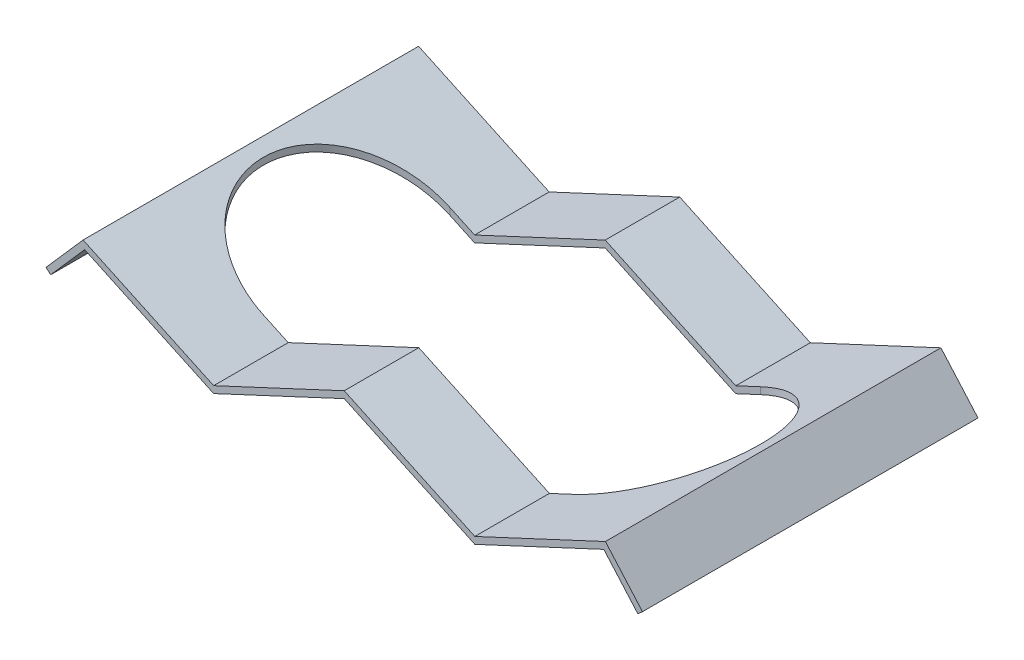
from build123d import *

# Parameters (mm, degrees)
EXTRU_MINCE1_DEPTH           = 13.5
ENL_V_MAT_EXTRU_1_DEPTH      = 3.45
ENL_V_MAT_EXTRU_1_DEPTH_BACK = 4.001688959


with BuildPart() as part:
    # Esquisse1 → Extru.-Mince1 (new body, symmetric)
    with BuildSketch(Plane.XY):
        Polygon((-24, -0.95), (-21.016167821, 2.45), (-10.50808391, -2.45), (0, 2.45), (10.50808391, -2.45), (21.016167821, 2.45), (24, -0.95), (23.624195852, -1.279804855), (20.887672756, 1.838392808), (10.50808391, -3.001688959), (0, 1.898311041), (-10.50808391, -3.001688959), (-20.887672756, 1.838392808), (-23.624195852, -1.279804855), align=None)
    extrude(amount=EXTRU_MINCE1_DEPTH, both=True)

    # Esquisse2 → Enlèv. mat.-Extru.1 (cut, two sides)
    with BuildSketch(Plane(origin=(0, 0, 0), x_dir=(1, 0, 0), z_dir=(0, 1, 0))) as enl_v_mat_extru_1_sk:
        with BuildLine():
            Line((-12.5, 7.5), (12.5, 7.5))
            ThreePointArc((12.5, 7.5), (20, 0), (12.5, -7.5))
            Line((12.5, -7.5), (-12.5, -7.5))
            ThreePointArc((-12.5, -7.5), (-20, 0), (-12.5, 7.5))
        make_face()
    extrude(amount=ENL_V_MAT_EXTRU_1_DEPTH, mode=Mode.SUBTRACT)
    extrude(enl_v_mat_extru_1_sk.sketch, amount=-ENL_V_MAT_EXTRU_1_DEPTH_BACK, mode=Mode.SUBTRACT)


solid = part.part
